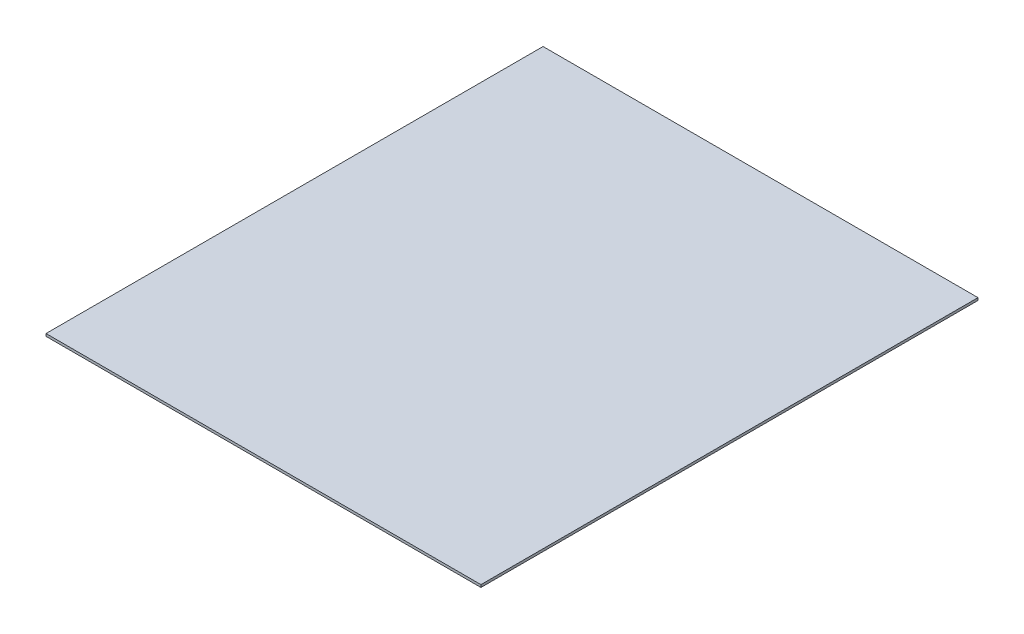
from build123d import *

# Parameters (mm, degrees)
SKETCH_1_W      = 400
SKETCH_1_H      = 2
EXTRUDE_1_DEPTH = 175


with BuildPart() as part:
    # 草图1 → 凸台-拉伸1 (new body, symmetric)
    with BuildSketch(Plane(origin=(0, 0, 0), x_dir=(0, 0, -1), z_dir=(1, 0, 0))):
        with Locations((0, -1)):
            Rectangle(SKETCH_1_W, SKETCH_1_H)
    extrude(amount=EXTRUDE_1_DEPTH, both=True)


solid = part.part
